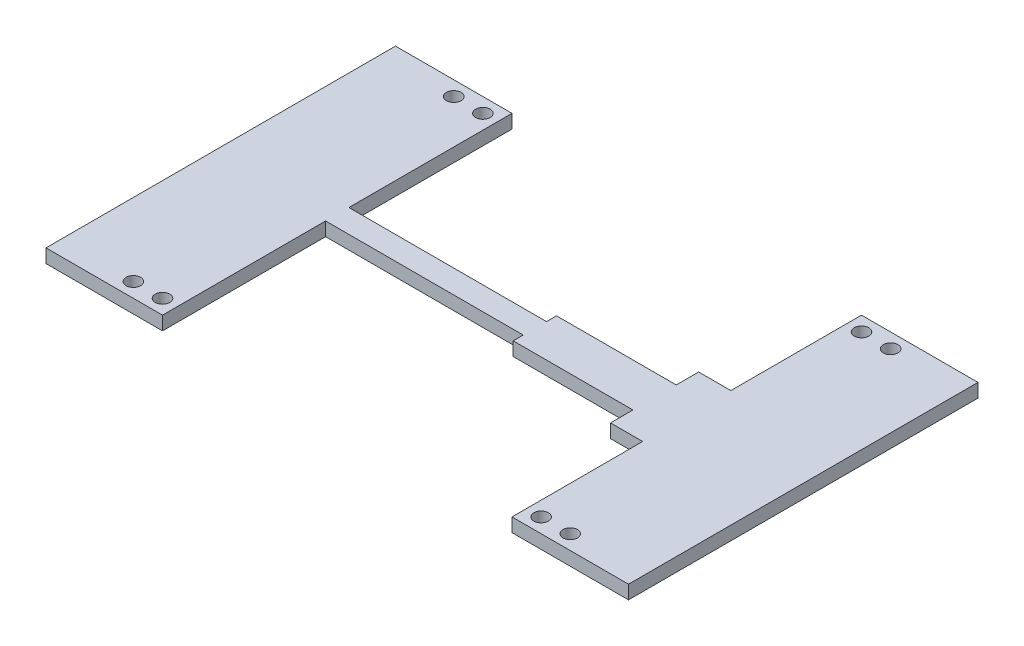
from build123d import *

# Parameters (mm, degrees)
SKETCH2_W           = 127
SKETCH2_H           = 76.2
BOSS_EXTRUDE1_DEPTH = 2.9718
SKETCH3_R           = 1.5875
CUT_EXTRUDE1_DEPTH  = 2.9718


with BuildPart() as part:
    # Sketch2 → Boss-Extrude1 (new body)
    with BuildSketch(Plane(origin=(0, 0, 0), x_dir=(1, 0, 0), z_dir=(0, 1, 0))):
        Rectangle(SKETCH2_W, SKETCH2_H)
    extrude(amount=BOSS_EXTRUDE1_DEPTH)

    # Sketch3 → Cut-Extrude1 (cut)
    with BuildSketch(Plane(origin=(0, 2.9718, 0), x_dir=(1, 0, 0), z_dir=(0, 1, 0))):
        Polygon((4.978749596, -4.724789245), (4.978749596, -2.54), (-38.1, -2.54), (-38.1, -38.1), (38.1, -38.1), (38.1, -9.614135395), (31.086734384, -9.614135395), (31.086734384, -4.724789245), align=None)
        with Locations((41.275, -34.925)):
            Circle(SKETCH3_R)
        with Locations((47.625, -34.925)):
            Circle(SKETCH3_R)
        with Locations((-41.275, -34.925)):
            Circle(SKETCH3_R)
        with Locations((-47.625, -34.925)):
            Circle(SKETCH3_R)
    cut_extrude1 = extrude(amount=-CUT_EXTRUDE1_DEPTH, mode=Mode.SUBTRACT)

    # Mirror1: Cut-Extrude1 across plane
    add(cut_extrude1.mirror(Plane.XY), mode=Mode.SUBTRACT)


solid = part.part
